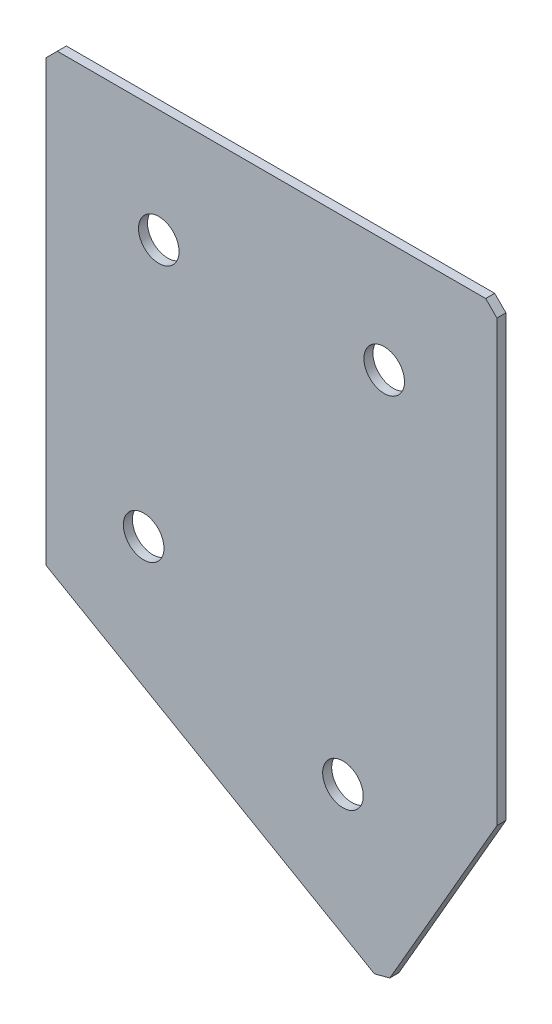
from build123d import *

# Parameters (mm, degrees)
EXTRUDE_1_DEPTH   = 2
HOLE_WIZARD_M81_D = 9
CHAMFER_1_SIZE    = 2.5


with BuildPart() as part:
    # Эскиз3 → Бобышка-Вытянуть1 (new body)
    with BuildSketch(Plane(origin=(0, 0, 0), x_dir=(1, 0, 0), z_dir=(0, 0, -1))):
        Polygon((0, 0), (100, 0), (100, 100), (75, 143.301270189), (0, 100), align=None)
    extrude(amount=EXTRUDE_1_DEPTH)

    # Отверстие с зазором M81 (through all)
    with Locations(Plane(origin=(0, 0, -2), x_dir=(1, 0, 0), z_dir=(0, 0, -1))):
        with Locations((25, 25), (75, 25), (21.650635095, 83.632486541), (65.849364905, 109.150635095)):
            Hole(HOLE_WIZARD_M81_D / 2)

    # Фаска1
    chamfer_1_edges = [part.edges().sort_by_distance(p)[0] for p in [
        (75, -143.301270189, -1),
        (100, 0, -1),
        (0, 0, -1),
    ]]
    chamfer(chamfer_1_edges, length=CHAMFER_1_SIZE)


solid = part.part
